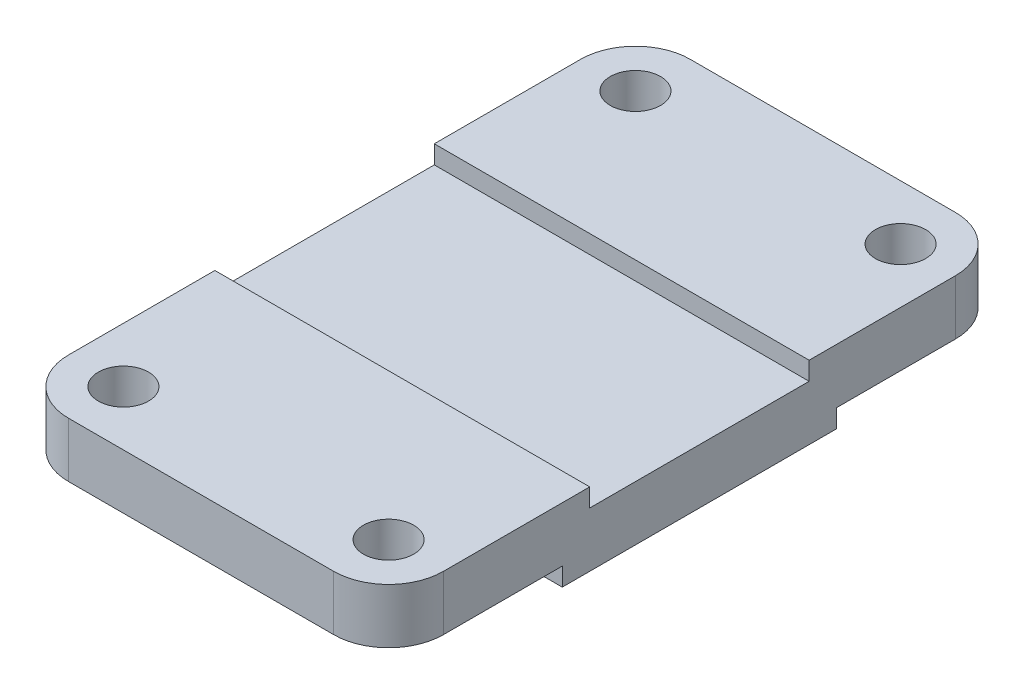
from build123d import *

# Parameters (mm, degrees)
SALIENTE_EXTRUIR3_DEPTH = 16
CROQUIS6_R              = 5.5
CORTAR_EXTRUIR3_DEPTH   = 17
CORTAR_EXTRUIR4_DEPTH   = 83
CROQUIS8_W              = 18
CROQUIS8_H              = 4
CROQUIS8_W_2            = 12
CORTAR_EXTRUIR5_DEPTH   = 83
CROQUIS9_W              = 8
CROQUIS9_H              = 4
CORTAR_EXTRUIR6_DEPTH   = 83
CROQUIS10_W             = 7
CROQUIS10_H             = 4
SALIENTE_EXTRUIR4_DEPTH = 82
CROQUIS11_W             = 7
CROQUIS11_H             = 4
SALIENTE_EXTRUIR5_DEPTH = 82


with BuildPart() as part:
    # Croquis1 → Saliente-Extruir3 (new body)
    with BuildSketch(Plane(origin=(0, 0, 0), x_dir=(1, 0, 0), z_dir=(0, 1, 0))):
        with BuildLine():
            Line((-29, 68), (29, 68))
            ThreePointArc((29, 68), (37.485281374, 64.485281374), (41, 56))
            Line((41, 56), (41, -56))
            ThreePointArc((41, -56), (37.485281374, -64.485281374), (29, -68))
            Line((29, -68), (-29, -68))
            ThreePointArc((-29, -68), (-37.485281374, -64.485281374), (-41, -56))
            Line((-41, -56), (-41, 56))
            ThreePointArc((-41, 56), (-37.485281374, 64.485281374), (-29, 68))
        make_face()
    extrude(amount=SALIENTE_EXTRUIR3_DEPTH)

    # Croquis6 → Cortar-Extruir3 (cut, through all)
    with BuildSketch(Plane(origin=(0, 16, 0), x_dir=(1, 0, 0), z_dir=(0, 1, 0))):
        with Locations((-29, 56)):
            Circle(CROQUIS6_R)
        with Locations((29, 56)):
            Circle(CROQUIS6_R)
        with Locations((-29, -56)):
            Circle(CROQUIS6_R)
        with Locations((29, -56)):
            Circle(CROQUIS6_R)
    extrude(amount=-CORTAR_EXTRUIR3_DEPTH, mode=Mode.SUBTRACT)

    # Croquis7 → Cortar-Extruir4 (cut, through all)
    with BuildSketch(Plane.ZY.offset(41)):
        Polygon((0, 16), (-38, 16), (-38, 12), (38, 12), (38, 16), align=None)
    extrude(amount=-CORTAR_EXTRUIR4_DEPTH, mode=Mode.SUBTRACT)

    # Croquis8 → Cortar-Extruir5 (cut, through all)
    with BuildSketch(Plane.ZY.offset(41)):
        with Locations((-47, 2)):
            Rectangle(CROQUIS8_W, CROQUIS8_H)
        with Locations((-62, 2)):
            Rectangle(CROQUIS8_W_2, CROQUIS8_H)
        with Locations((47, 2)):
            Rectangle(CROQUIS8_W, CROQUIS8_H)
        with Locations((62, 2)):
            Rectangle(CROQUIS8_W_2, CROQUIS8_H)
    extrude(amount=-CORTAR_EXTRUIR5_DEPTH, mode=Mode.SUBTRACT)

    # Croquis9 → Cortar-Extruir6 (cut, through all)
    with BuildSketch(Plane.ZY.offset(41)):
        with Locations((34, 2)):
            Rectangle(CROQUIS9_W, CROQUIS9_H)
        with Locations((-34, 2)):
            Rectangle(CROQUIS9_W, CROQUIS9_H)
    extrude(amount=-CORTAR_EXTRUIR6_DEPTH, mode=Mode.SUBTRACT)

    # Croquis10 → Saliente-Extruir4 (add)
    with BuildSketch(Plane.ZY.offset(41)):
        with Locations((-34.5, 14)):
            Rectangle(CROQUIS10_W, CROQUIS10_H)
        with Locations((34.5, 14)):
            Rectangle(CROQUIS10_W, CROQUIS10_H)
    extrude(amount=-SALIENTE_EXTRUIR4_DEPTH)

    # Croquis11 → Saliente-Extruir5 (add)
    with BuildSketch(Plane.ZY.offset(41)):
        with Locations((-27.5, 14)):
            Rectangle(CROQUIS11_W, CROQUIS11_H)
        with Locations((27.5, 14)):
            Rectangle(CROQUIS11_W, CROQUIS11_H)
    extrude(amount=-SALIENTE_EXTRUIR5_DEPTH)


solid = part.part
